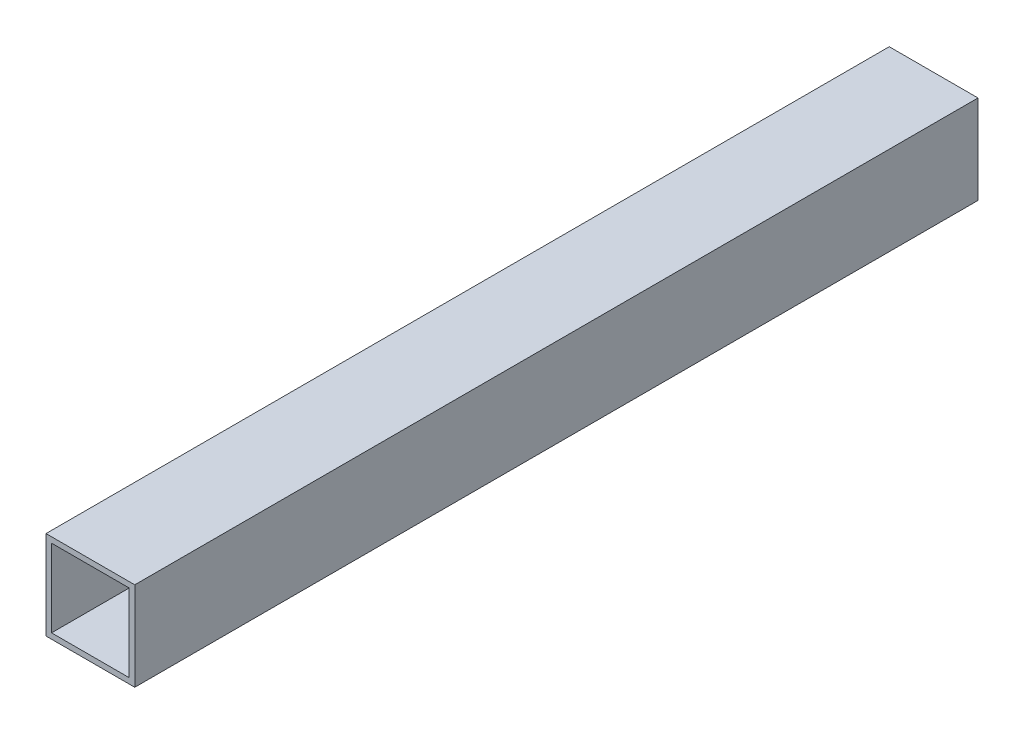
from build123d import *

# Parameters (mm, degrees)
SKETCH1_W           = 50.8
SKETCH1_H           = 50.8
SKETCH1_W_2         = 44.45
SKETCH1_H_2         = 44.45
BOSS_EXTRUDE1_DEPTH = 482.6


with BuildPart() as part:
    # Sketch1 → Boss-Extrude1 (new body)
    with BuildSketch(Plane.XY):
        with Locations((25.4, 25.4)):
            Rectangle(SKETCH1_W, SKETCH1_H)
        with Locations((25.4, 25.4)):
            Rectangle(SKETCH1_W_2, SKETCH1_H_2, mode=Mode.SUBTRACT)
    extrude(amount=BOSS_EXTRUDE1_DEPTH)


solid = part.part
